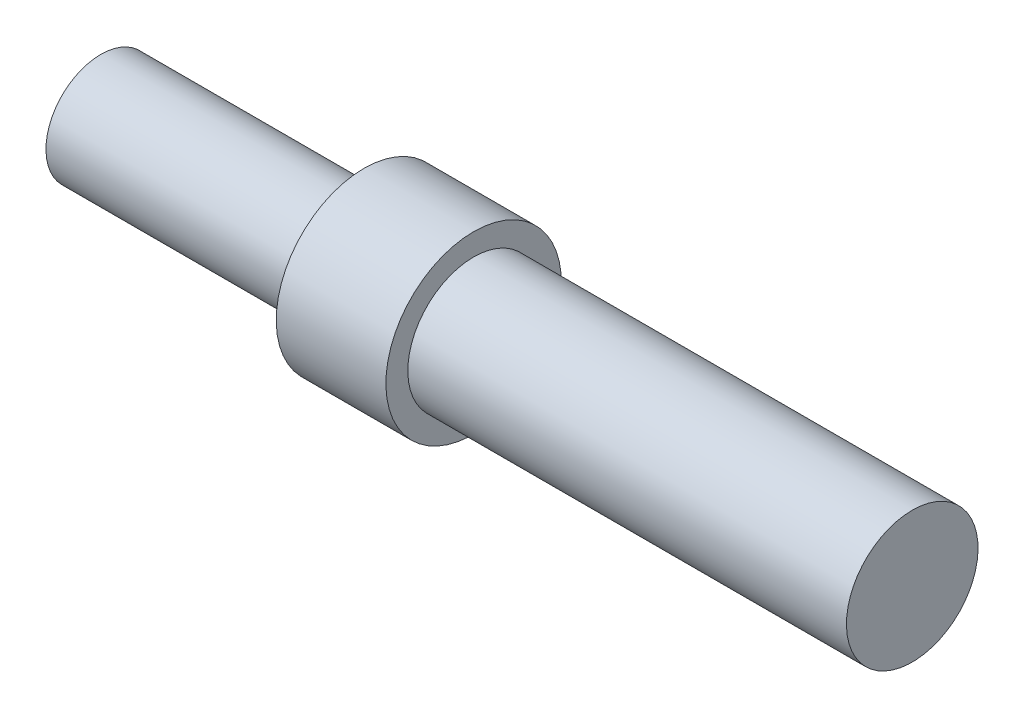
from build123d import *


with BuildPart() as part:
    # Sketch1 → Revolve1 (revolve)
    with BuildSketch(Plane.XY):
        Polygon((0, 0), (0, 1.25), (6, 1.25), (6, 2), (8.5, 2), (8.5, 1.5), (18.5, 1.5), (18.5, 0), align=None)
    revolve(axis=Axis((18.5, 0, 0), (-1, 0, 0)))


solid = part.part
